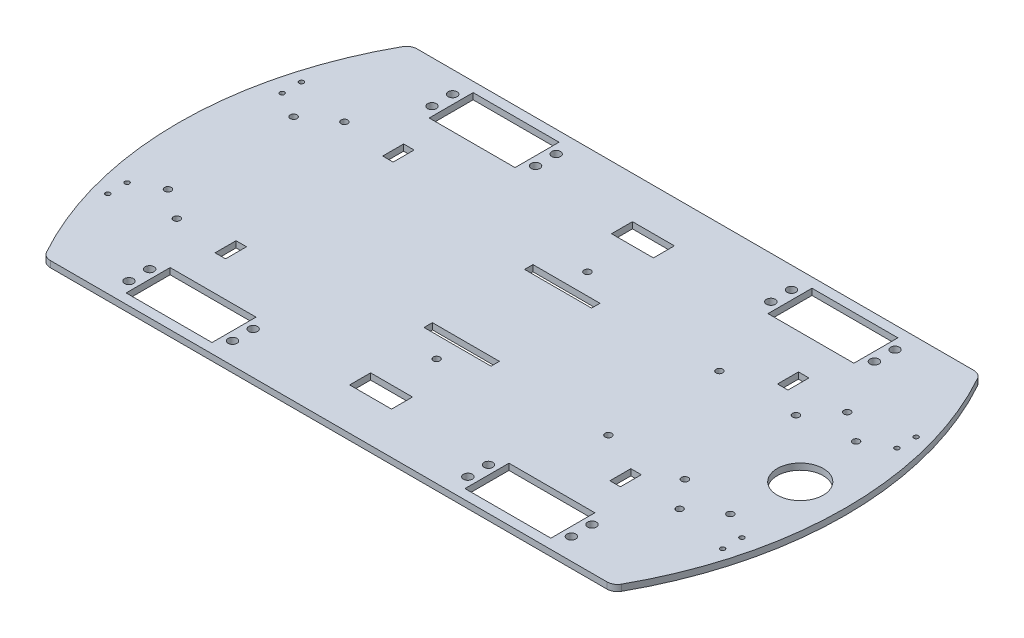
from build123d import *

# Parameters (mm, degrees)
SKETCH1_R           = 1.6
SKETCH1_R_2         = 1.1
SKETCH1_R_3         = 2.1
SKETCH1_R_4         = 11
SKETCH1_W           = 32
SKETCH1_H           = 4
SKETCH1_W_2         = 20
SKETCH1_H_2         = 10
SKETCH1_W_3         = 41
SKETCH1_H_3         = 21
SKETCH1_W_4         = 5
BOSS_EXTRUDE1_DEPTH = 3
FILLET1_R           = 5


with BuildPart() as part:
    # Sketch1 → Boss-Extrude1 (new body)
    with BuildSketch(Plane(origin=(0, 0, 0), x_dir=(1, 0, 0), z_dir=(0, 1, 0))):
        with BuildLine():
            Line((-126.554445662, 87.5), (-104.054445662, 87.5))
            Line((-104.054445662, 87.5), (-18.218162556, 87.5))
            Line((-18.218162556, 87.5), (40.836283106, 87.5))
            Line((40.836283106, 87.5), (120.836283106, 87.5))
            Line((120.836283106, 87.5), (137.792290187, 87.5))
            Line((137.792290187, 87.5), (145.014445662, 87.5))
            ThreePointArc((145.014445662, 87.5), (168.46, 0), (145.014445662, -87.5))
            Line((145.014445662, -87.5), (137.792290187, -87.5))
            Line((137.792290187, -87.5), (120.836283106, -87.5))
            Line((120.836283106, -87.5), (40.836283106, -87.5))
            Line((40.836283106, -87.5), (-18.218162556, -87.5))
            Line((-18.218162556, -87.5), (-104.054445662, -87.5))
            Line((-104.054445662, -87.5), (-126.554445662, -87.5))
            ThreePointArc((-126.554445662, -87.5), (-150, 0), (-126.554445662, 87.5))
        make_face()
        with Locations((-110.77, 40)):
            Circle(SKETCH1_R, mode=Mode.SUBTRACT)
        with Locations((-110.77, -40)):
            Circle(SKETCH1_R, mode=Mode.SUBTRACT)
        with Locations((-125, -30)):
            Circle(SKETCH1_R, mode=Mode.SUBTRACT)
        with Locations((9.23, -36)):
            Circle(SKETCH1_R, mode=Mode.SUBTRACT)
        with Locations((143.46, -30)):
            Circle(SKETCH1_R, mode=Mode.SUBTRACT)
        with Locations((143.46, 30)):
            Circle(SKETCH1_R, mode=Mode.SUBTRACT)
        with Locations((9.23, 36)):
            Circle(SKETCH1_R, mode=Mode.SUBTRACT)
        with Locations((-125, 30)):
            Circle(SKETCH1_R, mode=Mode.SUBTRACT)
        with Locations((-137.5, 37)):
            Circle(SKETCH1_R_2, mode=Mode.SUBTRACT)
        with Locations((-137.5, 46.2)):
            Circle(SKETCH1_R_2, mode=Mode.SUBTRACT)
        with Locations((-137.5, -37)):
            Circle(SKETCH1_R_2, mode=Mode.SUBTRACT)
        with Locations((-137.5, -46.2)):
            Circle(SKETCH1_R_2, mode=Mode.SUBTRACT)
        with Locations((65.39, -77.245)):
            Circle(SKETCH1_R_3, mode=Mode.SUBTRACT)
        with Locations((65.39, -67.395)):
            Circle(SKETCH1_R_3, mode=Mode.SUBTRACT)
        with Locations((114.812291, -77.245)):
            Circle(SKETCH1_R_3, mode=Mode.SUBTRACT)
        with Locations((114.812291, -67.395)):
            Circle(SKETCH1_R_3, mode=Mode.SUBTRACT)
        with Locations((114.812291, 67.395)):
            Circle(SKETCH1_R_3, mode=Mode.SUBTRACT)
        with Locations((114.812291, 77.245)):
            Circle(SKETCH1_R_3, mode=Mode.SUBTRACT)
        with Locations((65.39, 67.395)):
            Circle(SKETCH1_R_3, mode=Mode.SUBTRACT)
        with Locations((65.39, 77.245)):
            Circle(SKETCH1_R_3, mode=Mode.SUBTRACT)
        with Locations((155.96, 37)):
            Circle(SKETCH1_R_2, mode=Mode.SUBTRACT)
        with Locations((155.96, 46.2)):
            Circle(SKETCH1_R_2, mode=Mode.SUBTRACT)
        with Locations((155.96, -46.2)):
            Circle(SKETCH1_R_2, mode=Mode.SUBTRACT)
        with Locations((155.96, -37)):
            Circle(SKETCH1_R_2, mode=Mode.SUBTRACT)
        with Locations((-46.927011093, -67.395)):
            Circle(SKETCH1_R_3, mode=Mode.SUBTRACT)
        with Locations((-46.927011093, -77.245)):
            Circle(SKETCH1_R_3, mode=Mode.SUBTRACT)
        with Locations((-96.349302093, -67.395)):
            Circle(SKETCH1_R_3, mode=Mode.SUBTRACT)
        with Locations((-96.349302093, -77.245)):
            Circle(SKETCH1_R_3, mode=Mode.SUBTRACT)
        with Locations((-96.349302093, 77.245)):
            Circle(SKETCH1_R_3, mode=Mode.SUBTRACT)
        with Locations((-96.349302093, 67.395)):
            Circle(SKETCH1_R_3, mode=Mode.SUBTRACT)
        with Locations((-46.927011093, 77.245)):
            Circle(SKETCH1_R_3, mode=Mode.SUBTRACT)
        with Locations((-46.927011093, 67.395)):
            Circle(SKETCH1_R_3, mode=Mode.SUBTRACT)
        with Locations((129.23, 40)):
            Circle(SKETCH1_R, mode=Mode.SUBTRACT)
        with Locations((129.23, -40)):
            Circle(SKETCH1_R, mode=Mode.SUBTRACT)
        with Locations((81.75, 26.5)):
            Circle(SKETCH1_R, mode=Mode.SUBTRACT)
        with Locations((146.828017544, 0)):
            Circle(SKETCH1_R_4, mode=Mode.SUBTRACT)
        with Locations((118.25, 26.5)):
            Circle(SKETCH1_R, mode=Mode.SUBTRACT)
        with Locations((81.75, -26.5)):
            Circle(SKETCH1_R, mode=Mode.SUBTRACT)
        with Locations((118.25, -26.5)):
            Circle(SKETCH1_R, mode=Mode.SUBTRACT)
        with Locations((9.23, 24)):
            Rectangle(SKETCH1_W, SKETCH1_H, mode=Mode.SUBTRACT)
        with Locations((9.23, -24)):
            Rectangle(SKETCH1_W, SKETCH1_H, mode=Mode.SUBTRACT)
        with Locations((9.23, 62.5)):
            Rectangle(SKETCH1_W_2, SKETCH1_H_2, mode=Mode.SUBTRACT)
        with Locations((9.23, -62.5)):
            Rectangle(SKETCH1_W_2, SKETCH1_H_2, mode=Mode.SUBTRACT)
        with Locations((90.1, 72.32)):
            Rectangle(SKETCH1_W_3, SKETCH1_H_3, mode=Mode.SUBTRACT)
        with Locations((90.1, -72.32)):
            Rectangle(SKETCH1_W_3, SKETCH1_H_3, mode=Mode.SUBTRACT)
        with Locations((-71.637011093, 72.32)):
            Rectangle(SKETCH1_W_3, SKETCH1_H_3, mode=Mode.SUBTRACT)
        with Locations((-71.637011093, -72.32)):
            Rectangle(SKETCH1_W_3, SKETCH1_H_3, mode=Mode.SUBTRACT)
        with Locations((-85, 40)):
            Rectangle(SKETCH1_W_4, SKETCH1_H_2, mode=Mode.SUBTRACT)
        with Locations((-85, -40)):
            Rectangle(SKETCH1_W_4, SKETCH1_H_2, mode=Mode.SUBTRACT)
        with Locations((103.46, 40)):
            Rectangle(SKETCH1_W_4, SKETCH1_H_2, mode=Mode.SUBTRACT)
        with Locations((103.46, -40)):
            Rectangle(SKETCH1_W_4, SKETCH1_H_2, mode=Mode.SUBTRACT)
    extrude(amount=BOSS_EXTRUDE1_DEPTH)

    # Fillet1
    fillet1_edges = [part.edges().sort_by_distance(p)[0] for p in [
        (-126.554445662, 1.5, 87.5),
        (-126.554445662, 1.5, -87.5),
        (145.014445662, 1.5, -87.5),
        (145.014445662, 1.5, 87.5),
    ]]
    fillet(fillet1_edges, radius=FILLET1_R)


solid = part.part
